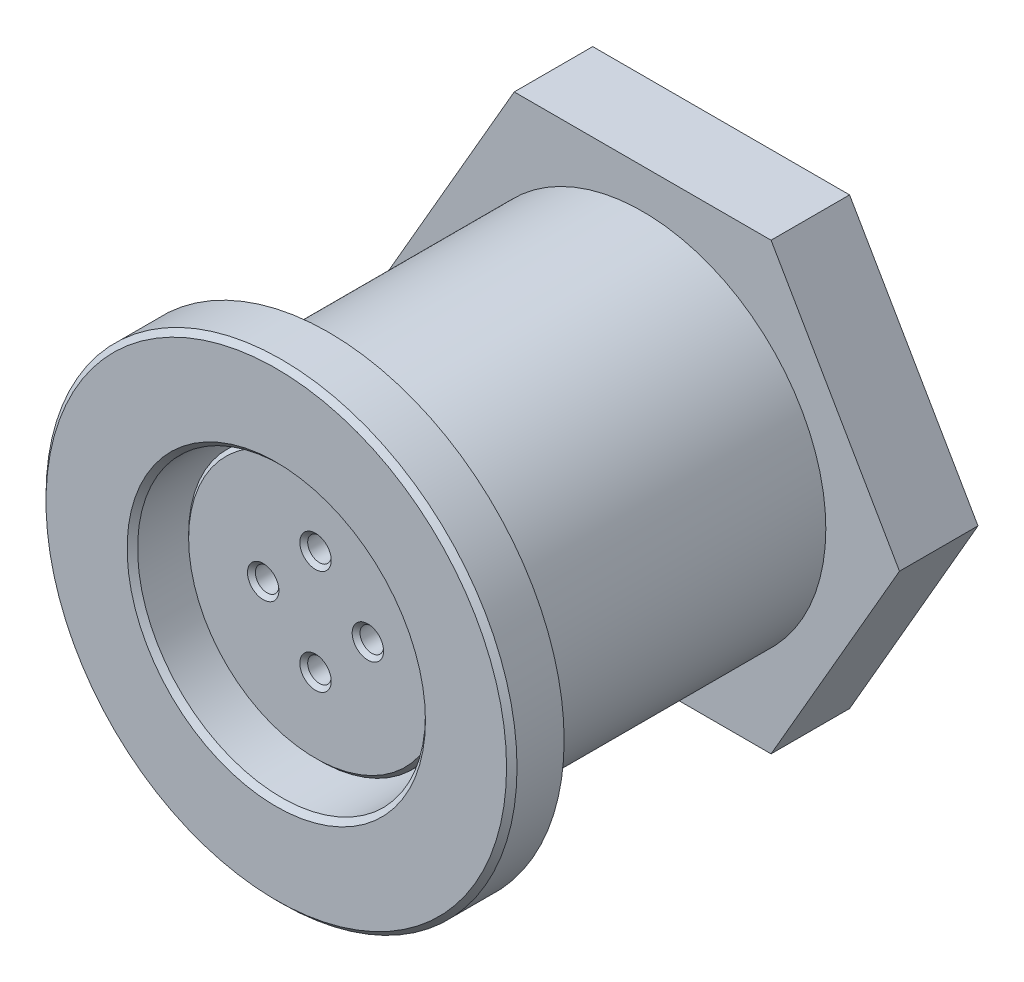
from build123d import *

# Parameters (mm, degrees)
SKETCH1_R          = 9
EXTRUDE1_DEPTH     = 2
SKETCH4_R          = 7
EXTRUDE2_DEPTH     = 16
SKETCH2_R          = 5.5
CUT_EXTRUDE1_DEPTH = 10
SKETCH3_R          = 8.25
SKETCH3_R_2        = 7
CUT_EXTRUDE2_DEPTH = 1
SKETCH5_R          = 5
EXTRUDE3_DEPTH     = 8.5
SKETCH6_R          = 0.45
CUT_EXTRUDE3_DEPTH = 7
CHAMFER2_SIZE      = 0.15
CHAMFER1_SIZE      = 0.2
SKETCH7_R          = 5.5
CUT_EXTRUDE4_DEPTH = 1
CHAMFER3_SIZE      = 0.5
EXTRUDE4_DEPTH     = 3


with BuildPart() as part:
    # Sketch1 → Extrude1 (new body)
    with BuildSketch(Plane.XY):
        Circle(SKETCH1_R)
    extrude(amount=EXTRUDE1_DEPTH)

    # Sketch4 → Extrude2 (add)
    with BuildSketch(Plane(origin=(0, 0, 0), x_dir=(-1, 0, 0), z_dir=(0, 0, -1))):
        Circle(SKETCH4_R)
    extrude(amount=EXTRUDE2_DEPTH)

    # Sketch2 → Cut-Extrude1 (cut)
    with BuildSketch(Plane.XY.offset(2)):
        Circle(SKETCH2_R)
    extrude(amount=-CUT_EXTRUDE1_DEPTH, mode=Mode.SUBTRACT)

    # Sketch3 → Cut-Extrude2 (cut)
    with BuildSketch(Plane(origin=(0, 0, 0), x_dir=(-1, 0, 0), z_dir=(0, 0, -1))):
        Circle(SKETCH3_R)
        Circle(SKETCH3_R_2, mode=Mode.SUBTRACT)
    extrude(amount=-CUT_EXTRUDE2_DEPTH, mode=Mode.SUBTRACT)

    # Sketch5 → Extrude3 (add)
    with BuildSketch(Plane.XY.offset(-8)):
        Circle(SKETCH5_R)
    extrude(amount=EXTRUDE3_DEPTH)

    # Sketch6 → Cut-Extrude3 (cut)
    with BuildSketch(Plane.XY.offset(0.5)):
        with Locations((0, 2)):
            Circle(SKETCH6_R)
        with Locations((0, -2)):
            Circle(SKETCH6_R)
        with Locations((2, 0)):
            Circle(SKETCH6_R)
        with Locations((-2, 0)):
            Circle(SKETCH6_R)
    extrude(amount=-CUT_EXTRUDE3_DEPTH, mode=Mode.SUBTRACT)

    # Chamfer2
    chamfer2_edges = [part.edges().sort_by_distance(p)[0] for p in [
        (-5, 0, 0.5),
        (-0.45, 2, 0.5),
        (-0.45, -2, 0.5),
        (1.55, 0, 0.5),
        (-2.45, 0, 0.5),
    ]]
    chamfer(chamfer2_edges, length=CHAMFER2_SIZE)

    # Chamfer1
    chamfer1_edges = [part.edges().sort_by_distance(p)[0] for p in [
        (-5.5, 0, 2),
        (-9, 0, 2),
    ]]
    chamfer(chamfer1_edges, length=CHAMFER1_SIZE)

    # Sketch7 → Cut-Extrude4 (cut)
    with BuildSketch(Plane(origin=(0, 0, -16), x_dir=(-1, 0, 0), z_dir=(0, 0, -1))):
        Circle(SKETCH7_R)
    extrude(amount=-CUT_EXTRUDE4_DEPTH, mode=Mode.SUBTRACT)

    # Chamfer3
    chamfer3_edges = [part.edges().sort_by_distance(p)[0] for p in [
        (7, 0, -16),
    ]]
    chamfer(chamfer3_edges, length=CHAMFER3_SIZE)

    # Sketch8 → Extrude4 (add)
    with BuildSketch(Plane(origin=(0, 0, -15), x_dir=(-1, 0, 0), z_dir=(0, 0, -1))):
        Polygon((-4.907477288, 8.5), (4.907477288, 8.5), (9.814954576, 0), (4.907477288, -8.5), (-4.907477288, -8.5), (-9.814954576, 0), align=None)
    extrude(amount=-EXTRUDE4_DEPTH)


solid = part.part
